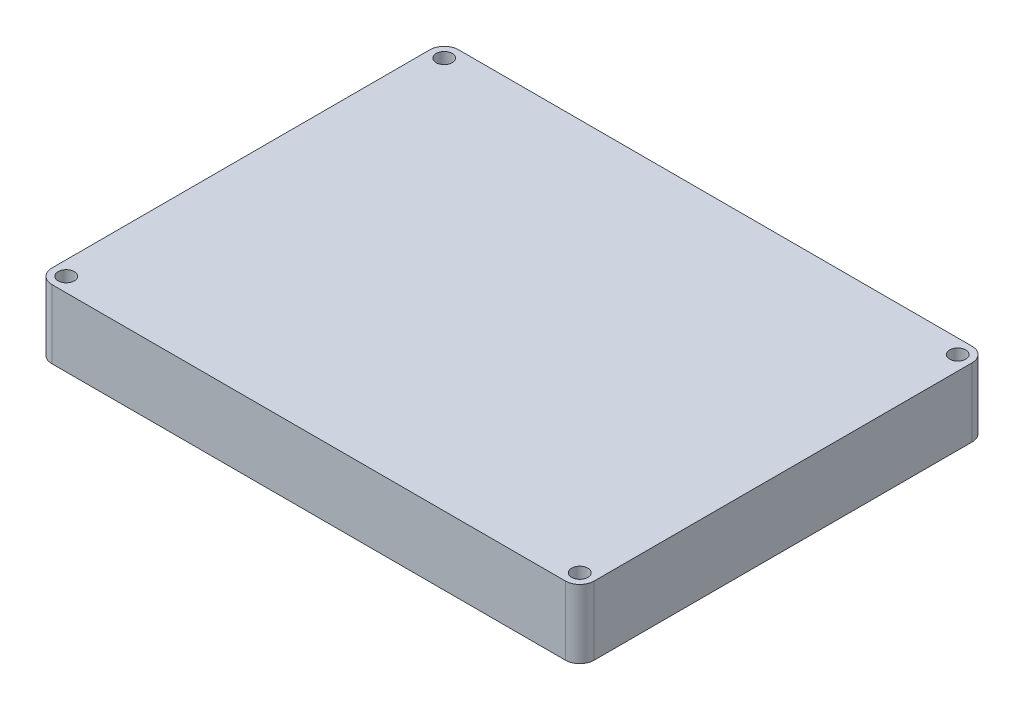
from build123d import *

# Parameters (mm, degrees)
BOSS_EXTRUDE1_START             = -5.98
BOSS_EXTRUDE1_DEPTH             = 15.18
F_9_64_0_14063_DIAMETER_HOLE1_D = 3.572002


with BuildPart() as part:
    # Sketch1 → Boss-Extrude1 (new body)
    with BuildSketch(Plane(origin=(0, 205.181102149, 0), x_dir=(1, 0, 0), z_dir=(0, 1, 0)).offset(BOSS_EXTRUDE1_START)):
        with BuildLine():
            Line((43.681940653, -244.079539284), (157.331940653, -244.079539284))
            ThreePointArc((157.331940653, -244.079539284), (159.577004684, -245.009475254), (160.506940653, -247.254539284))
            Line((160.506940653, -247.254539284), (160.506940653, -330.904539284))
            ThreePointArc((160.506940653, -330.904539284), (159.577004684, -333.149603314), (157.331940653, -334.079539284))
            Line((157.331940653, -334.079539284), (43.681940653, -334.079539284))
            ThreePointArc((43.681940653, -334.079539284), (41.436876623, -333.149603314), (40.506940653, -330.904539284))
            Line((40.506940653, -330.904539284), (40.506940653, -247.254539284))
            ThreePointArc((40.506940653, -247.254539284), (41.436876623, -245.009475254), (43.681940653, -244.079539284))
        make_face()
    extrude(amount=BOSS_EXTRUDE1_DEPTH)

    # 9/64 (0.14063) Diameter Hole1 (through all)
    with Locations(Plane(origin=(0, 214.381102149, 0), x_dir=(1, 0, 0), z_dir=(0, 1, 0))):
        with Locations((43.681940653, -330.904539284), (43.681940653, -247.254539284), (157.331940653, -247.254539284), (157.331940653, -330.904539284)):
            Hole(F_9_64_0_14063_DIAMETER_HOLE1_D / 2)


solid = part.part
